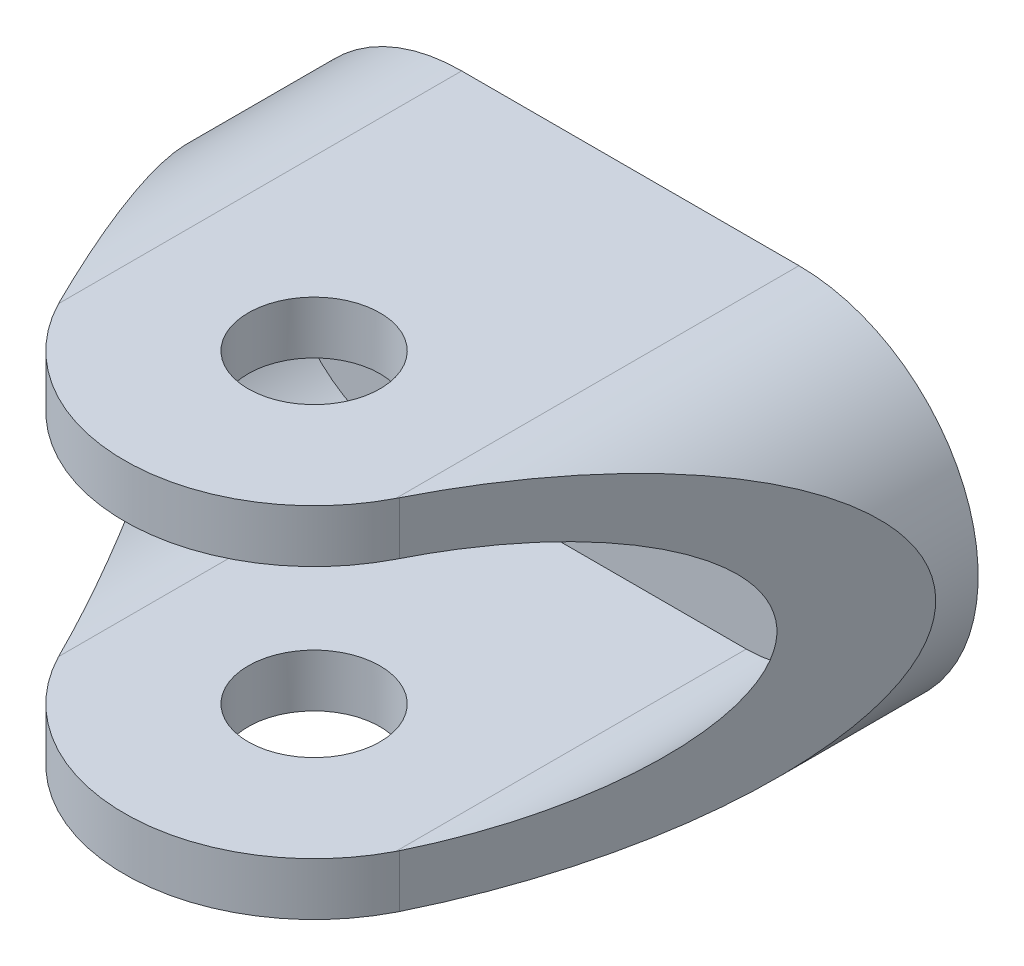
from build123d import *

# Parameters (mm, degrees)
SKETCH1_W          = 44.45
SKETCH1_H          = 31.75
BILLET_DEPTH       = 21.59
SKETCH2_R          = 3.96875
MILL_CUT_1_DEPTH   = 22.59
CUT_EXTRUDE1_DEPTH = 27.305
CUT_EXTRUDE2_DEPTH = 31.48
SKETCH9_R          = 3.175
HOLES_DEPTH        = 4.1750001


with BuildPart() as part:
    # Sketch1 → Billet (new body)
    with BuildSketch(Plane(origin=(0, 0, 0), x_dir=(1, 0, 0), z_dir=(0, 1, 0))):
        Rectangle(SKETCH1_W, SKETCH1_H)
    extrude(amount=BILLET_DEPTH)

    # Sketch2 → Mill Cut 1 (cut, through all)
    with BuildSketch(Plane(origin=(0, 21.59, 0), x_dir=(1, 0, 0), z_dir=(0, 1, 0))):
        with Locations((0, -3.175)):
            Circle(SKETCH2_R)
        with BuildLine():
            Line((-10.236684927, -8.259799082), (-22.225, 15.875))
            Line((-22.225, 15.875), (-22.225, -15.875))
            Line((-22.225, -15.875), (22.225, -15.875))
            Line((22.225, -15.875), (22.225, 15.875))
            Line((22.225, 15.875), (10.236684927, -8.259799082))
            ThreePointArc((10.236684927, -8.259799082), (0, -14.605), (-10.236684927, -8.259799082))
        make_face()
    extrude(amount=-MILL_CUT_1_DEPTH, mode=Mode.SUBTRACT)

    # Sketch6 → Cut-Extrude1 (cut)
    with BuildSketch(Plane(origin=(0, 21.59, 14.605), x_dir=(1, 0, 0), z_dir=(0, 0, 1))):
        with BuildLine():
            Line((-10.16, -3.175), (10.16, -3.175))
            ThreePointArc((10.16, -3.175), (17.78, -10.795), (10.16, -18.415))
            Line((10.16, -18.415), (-10.16, -18.415))
            ThreePointArc((-10.16, -18.415), (-17.78, -10.795), (-10.16, -3.175))
        make_face()
    extrude(amount=-CUT_EXTRUDE1_DEPTH, mode=Mode.SUBTRACT)

    # Sketch8 → Cut-Extrude2 (cut, through all)
    with BuildSketch(Plane(origin=(0, 21.59, 14.605), x_dir=(1, 0, 0), z_dir=(0, 0, 1))):
        with BuildLine():
            Line((-10.16, -21.59), (-60.96, -21.59))
            Line((-60.96, -21.59), (-60.96, 0))
            Line((-60.96, 0), (-10.16, 0))
            ThreePointArc((-10.16, 0), (-20.955, -10.795), (-10.16, -21.59))
        make_face()
    cut_extrude2 = extrude(amount=-CUT_EXTRUDE2_DEPTH, mode=Mode.SUBTRACT)

    # Mirror1: Cut-Extrude2 across plane
    add(cut_extrude2.mirror(Plane(origin=(0, 0, 0), x_dir=(0, 0, 1), z_dir=(1, 0, 0))), mode=Mode.SUBTRACT)

    # Sketch9 → Holes (cut, through all)
    with BuildSketch(Plane.XY.offset(-12.7)):
        with Locations((12.7, 10.795)):
            Circle(SKETCH9_R)
        with Locations((-12.7, 10.795)):
            Circle(SKETCH9_R)
    extrude(amount=-HOLES_DEPTH, mode=Mode.SUBTRACT)


solid = part.part
